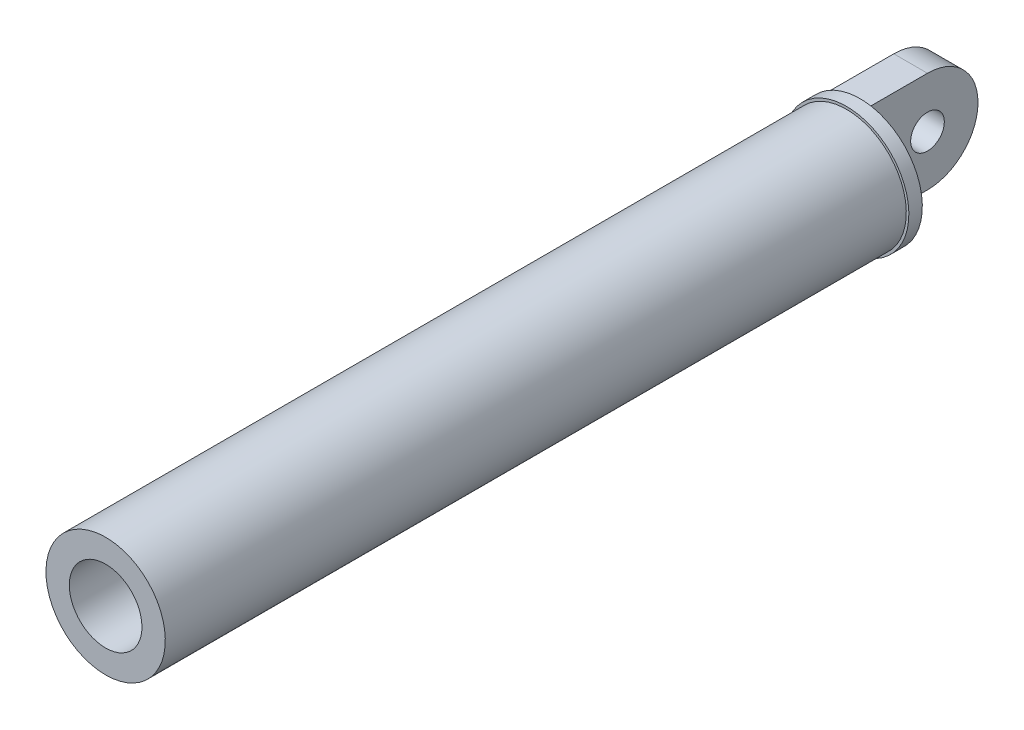
from build123d import *

# Parameters (mm, degrees)
SKETCH1_R           = 5
BOSS_EXTRUDE1_DEPTH = 5


with BuildPart() as part:
    # Sketch1 → Boss-Extrude1 (new body, symmetric)
    with BuildSketch(Plane(origin=(0, 0, 0), x_dir=(0, 0, -1), z_dir=(1, 0, 0))):
        with BuildLine():
            Line((0, 15), (-20, 15))
            Line((-20, 15), (-20, -15))
            Line((-20, -15), (0, -15))
            ThreePointArc((0, -15), (15, 0), (0, 15))
        make_face()
        Circle(SKETCH1_R, mode=Mode.SUBTRACT)
    extrude(amount=BOSS_EXTRUDE1_DEPTH, both=True)

    # Sketch3 → Revolve1 (revolve)
    with BuildSketch(Plane(origin=(5, 0, 0), x_dir=(0, 0, -1), z_dir=(1, 0, 0))):
        Polygon((-20, 1.817002653), (-20, 15), (-20, 15.485698602), (-20, 18.475930921), (-24, 18.475930921), (-24, 17.713484144), (-244, 17.713484144), (-244, 10.782192935), (-26, 10.782192935), (-26, 0), (-20, 0), align=None)
    revolve(axis=Axis((5, 0, 26), (0, 0, -1)))


solid = part.part
